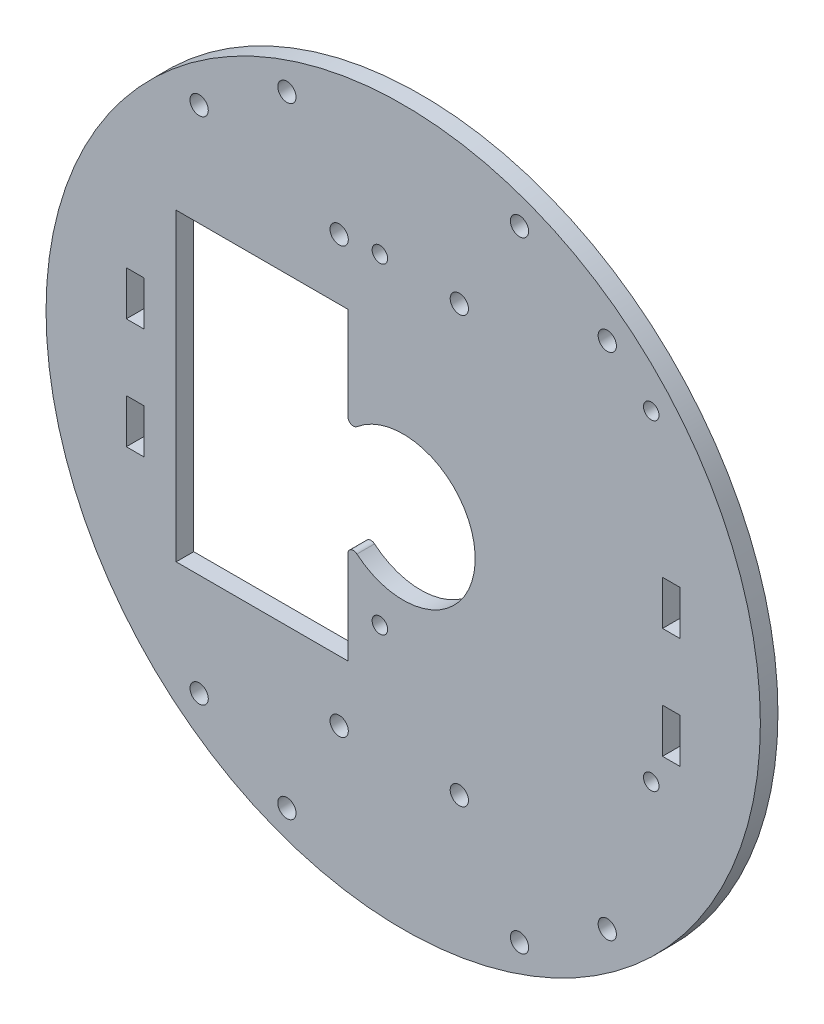
from build123d import *

# Parameters (mm, degrees)
SKETCH1_R           = 64.5
SKETCH1_R_2         = 1.65
SKETCH1_R_3         = 13
SKETCH1_R_4         = 1.4
BOSS_EXTRUDE2_DEPTH = 3.175
SKETCH2_W           = 3.175
SKETCH2_H           = 8
CUT_EXTRUDE1_DEPTH  = 4.175
SKETCH3_W           = 31
SKETCH3_H           = 55
CUT_EXTRUDE2_DEPTH  = 4.175
FILLET3_R           = 1


with BuildPart() as part:
    # Sketch1 → Boss-Extrude2 (new body)
    with BuildSketch(Plane(origin=(0, 0, 0), x_dir=(-1, 0, 0), z_dir=(0, 0, 1))):
        with Locations((14.45539036, 0.366425758)):
            Circle(SKETCH1_R)
        with Locations((26.018596538, -38.058574242)):
            Circle(SKETCH1_R_2, mode=Mode.SUBTRACT)
        with Locations((4.318596538, -38.058574242)):
            Circle(SKETCH1_R_2, mode=Mode.SUBTRACT)
        with Locations((26.018596538, 38.791425758)):
            Circle(SKETCH1_R_2, mode=Mode.SUBTRACT)
        with Locations((4.318596538, 38.791425758)):
            Circle(SKETCH1_R_2, mode=Mode.SUBTRACT)
        with Locations((14.45539036, 0.366425758)):
            Circle(SKETCH1_R_3, mode=Mode.SUBTRACT)
        with Locations((-6.54460964, 56.366425758)):
            Circle(SKETCH1_R_2, mode=Mode.SUBTRACT)
        with Locations((-22.394874657, 46.366425758)):
            Circle(SKETCH1_R_2, mode=Mode.SUBTRACT)
        with Locations((35.45539036, 56.366425758)):
            Circle(SKETCH1_R_2, mode=Mode.SUBTRACT)
        with Locations((51.305655378, 46.366425758)):
            Circle(SKETCH1_R_2, mode=Mode.SUBTRACT)
        with Locations((51.305655378, -45.633574242)):
            Circle(SKETCH1_R_2, mode=Mode.SUBTRACT)
        with Locations((35.45539036, -55.633574242)):
            Circle(SKETCH1_R_2, mode=Mode.SUBTRACT)
        with Locations((-6.54460964, -55.633574242)):
            Circle(SKETCH1_R_2, mode=Mode.SUBTRACT)
        with Locations((-22.394874657, -45.633574242)):
            Circle(SKETCH1_R_2, mode=Mode.SUBTRACT)
        with Locations((18.66683861, -38.633574242)):
            Circle(SKETCH1_R_4, mode=Mode.SUBTRACT)
        with Locations((-30.33316139, -38.633574242)):
            Circle(SKETCH1_R_4, mode=Mode.SUBTRACT)
        with Locations((18.66683861, 19.366425758)):
            Circle(SKETCH1_R_4, mode=Mode.SUBTRACT)
        with Locations((-30.33316139, 19.366425758)):
            Circle(SKETCH1_R_4, mode=Mode.SUBTRACT)
    extrude(amount=BOSS_EXTRUDE2_DEPTH)

    # Sketch2 → Cut-Extrude1 (cut, through all)
    with BuildSketch(Plane.XY.offset(3.175)):
        with Locations((33.95710964, -10.366425758)):
            Rectangle(SKETCH2_W, SKETCH2_H)
        with Locations((33.95710964, 9.633574242)):
            Rectangle(SKETCH2_W, SKETCH2_H)
        with Locations((-62.86789036, 9.633574242)):
            Rectangle(SKETCH2_W, SKETCH2_H)
        with Locations((-62.86789036, -10.366425758)):
            Rectangle(SKETCH2_W, SKETCH2_H)
    extrude(amount=-CUT_EXTRUDE1_DEPTH, mode=Mode.SUBTRACT)

    # Sketch3 → Cut-Extrude2 (cut, through all)
    with BuildSketch(Plane.XY.offset(3.175)):
        with Locations((-39.95539036, -0.366425758)):
            Rectangle(SKETCH3_W, SKETCH3_H)
    extrude(amount=-CUT_EXTRUDE2_DEPTH, mode=Mode.SUBTRACT)

    # Fillet3
    fillet3_edges = [part.edges().sort_by_distance(p)[0] for p in [
        (-24.45539036, 7.940198105, 1.5875),
        (-24.45539036, -8.673049621, 1.5875),
    ]]
    fillet(fillet3_edges, radius=FILLET3_R)


solid = part.part
